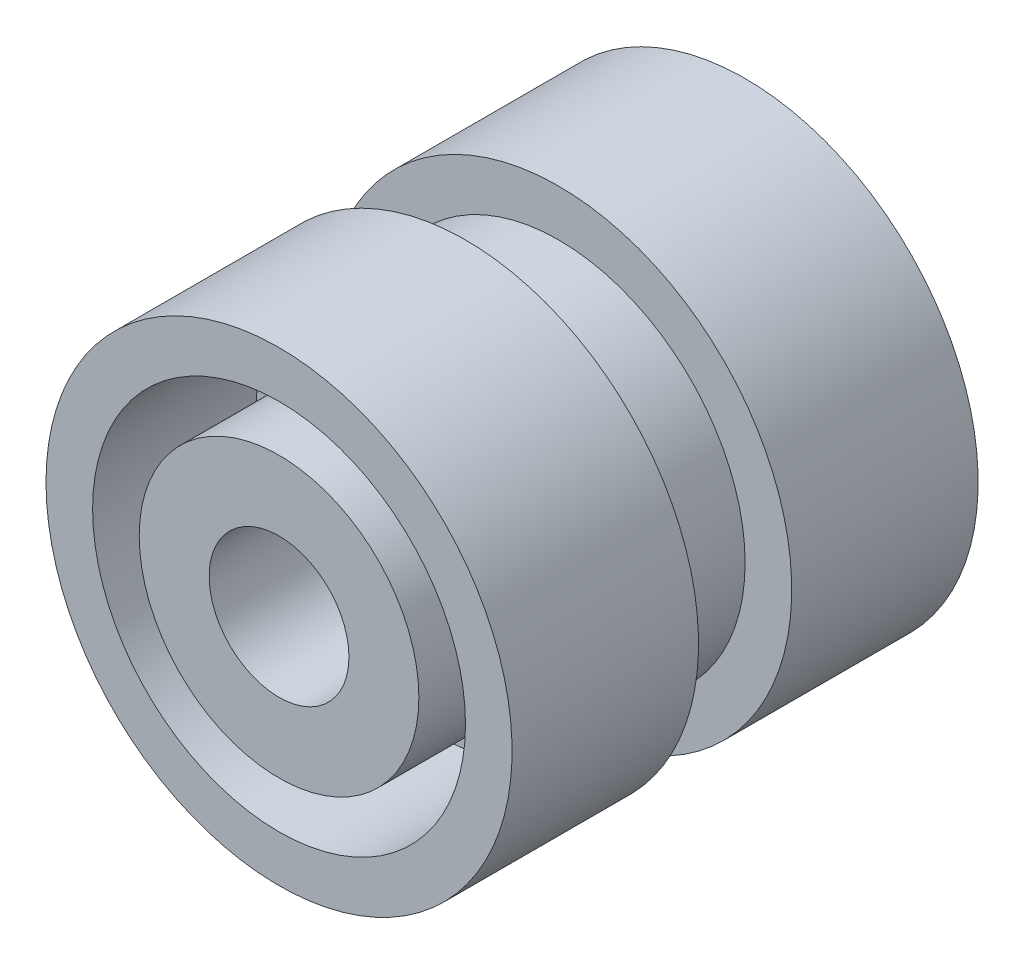
from build123d import *

# Parameters (mm, degrees)
BOSS_EXTRUDE1_DEPTH = 2
SKETCH3_R           = 1.5
CUT_EXTRUDE1_DEPTH  = 8


with BuildPart() as part:
    # Sketch1 → Revolve1 (revolve)
    with BuildSketch(Plane(origin=(0, 0, 0), x_dir=(0, 0, -1), z_dir=(1, 0, 0))):
        Polygon((0, 0), (-5, 0), (-5, 3), (-1.5, 3), (-1.5, 4), (-5, 4), (-5, 5), (-1, 5), (-1, 4), (1, 4), (1, 5), (5, 5), (5, 4), (1.5, 4), (1.5, 0), align=None)
    revolve(axis=Axis((0, 0, 0), (0, 0, 1)))

    # Sketch2 → Boss-Extrude1 (add)
    with BuildSketch(Plane(origin=(0, 0, -1.5), x_dir=(-1, 0, 0), z_dir=(0, 0, -1))):
        with BuildLine():
            Line((0.5, 1.936491673), (0.5, 3.968626967))
            ThreePointArc((0.5, 3.968626967), (0, 4), (-0.5, 3.968626967))
            Line((-0.5, 3.968626967), (-0.5, 1.936491673))
            ThreePointArc((-0.5, 1.936491673), (-1.414213562, 1.414213562), (-1.936491673, 0.5))
            Line((-1.936491673, 0.5), (-3.968626967, 0.5))
            ThreePointArc((-3.968626967, 0.5), (-4, 0), (-3.968626967, -0.5))
            Line((-3.968626967, -0.5), (-1.936491673, -0.5))
            ThreePointArc((-1.936491673, -0.5), (-1.414213562, -1.414213562), (-0.5, -1.936491673))
            Line((-0.5, -1.936491673), (-0.5, -3.968626967))
            ThreePointArc((-0.5, -3.968626967), (0, -4), (0.5, -3.968626967))
            Line((0.5, -3.968626967), (0.5, -1.936491673))
            ThreePointArc((0.5, -1.936491673), (1.414213562, -1.414213562), (1.936491673, -0.5))
            Line((1.936491673, -0.5), (3.968626967, -0.5))
            ThreePointArc((3.968626967, -0.5), (4, 0), (3.968626967, 0.5))
            Line((3.968626967, 0.5), (1.936491673, 0.5))
            ThreePointArc((1.936491673, 0.5), (1.414213562, 1.414213562), (0.5, 1.936491673))
        make_face()
    extrude(amount=BOSS_EXTRUDE1_DEPTH)

    # Sketch3 → Cut-Extrude1 (cut)
    with BuildSketch(Plane.XY.offset(5)):
        Circle(SKETCH3_R)
    extrude(amount=-CUT_EXTRUDE1_DEPTH, mode=Mode.SUBTRACT)


solid = part.part
